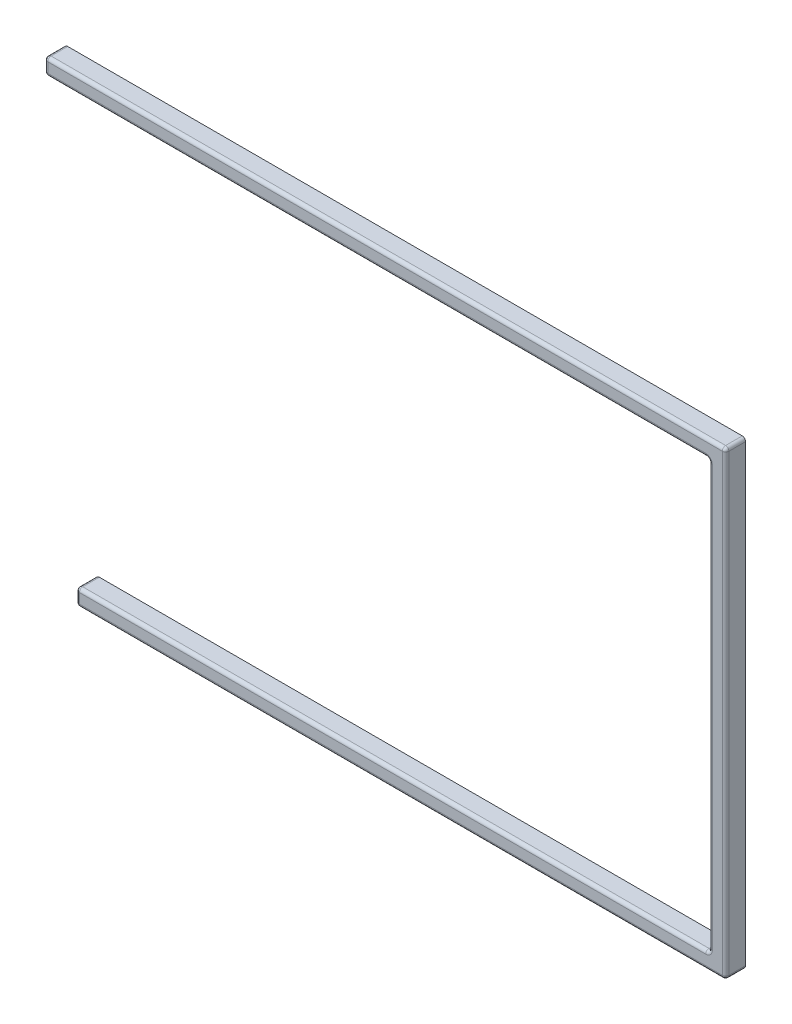
from build123d import *

# Parameters (mm, degrees)
MODEL_W                = 13.999
MODEL_H                = 13.99947
MODEL_W_2              = 13.9993
MODEL_H_2              = 13.99948
MODEL_W_3              = 14.0009
MODEL_H_3              = 13.9994
MODEL_W_4              = 14
MODEL_W_5              = 13.9994
MODEL_H_4              = 13.9992
MODEL_W_6              = 13.9998
MODEL_W_7              = 13.99955
MODEL_W_8              = 14.0007
MODEL_W_9              = 14.001
MODEL_W_10             = 13.99954
MODEL_H_5              = 13.999
EXTRUDE_1_DEPTH        = 3
EXTRUDE_START          = -3
EXTRUDE_2_DEPTH        = 6
CUT_EXTRUDE_START      = -3
SKETCH_2_R             = 1.25
CUT_EXTRUDE_1_DEPTH    = 3.5
FILLET_1_R             = 1
PATTERN_LINEAR_1_COUNT = 3
PATTERN_LINEAR_1_PITCH = 90
SKETCH_3_R             = 1.25
CUT_EXTRUDE_2_DEPTH    = 3.5
PATTERN_LINEAR_2_COUNT = 3
PATTERN_LINEAR_2_PITCH = 70
CUT_EXTRUDE_3_DEPTH    = 10
FILLET_2_R             = 1


with BuildPart() as part:
    # Model → 凸台-拉伸1 (new body)
    with BuildSketch(Plane.XY):
        Polygon((4.85693, 129.021), (204.883, 129.021), (204.883, 0.434082), (14.38193, 0.434082), (14.38193, 24.241), (23.90693, 24.241), (23.90693, 43.291), (14.38193, 43.291), (14.38193, 62.341), (9.61893, 62.341), (9.61893, 81.391), (0.09393, 81.391), (0.09393, 109.971), (4.85693, 109.971), align=None)
        with Locations((152.4945, 9.959765)):
            Rectangle(MODEL_W, MODEL_H, mode=Mode.SUBTRACT)
        with Locations((171.5445, 9.959765)):
            Rectangle(MODEL_W, MODEL_H, mode=Mode.SUBTRACT)
        with Locations((190.5945, 9.959765)):
            Rectangle(MODEL_W, MODEL_H, mode=Mode.SUBTRACT)
        Polygon((33.5759, 21.722), (33.5759, 17.0215), (32.0504, 17.0215), (32.0504, 20.2517), (30.3251, 20.2517), (30.3251, 21.1722), (27.0261, 21.1722), (27.0261, 20.2517), (25.3008, 20.2517), (25.3008, 17.0215), (24.4753, 17.0215), (24.4753, 14.2227), (25.3008, 14.2227), (25.3008, 7.95267), (27.0261, 7.95267), (27.0261, 6.97286), (30.3251, 6.97286), (30.3251, 7.95267), (32.0504, 7.95267), (32.0504, 12.4216), (33.5759, 12.4216), (33.5759, 7.72252), (47.5753, 7.72252), (47.5753, 12.4216), (49.101, 12.4216), (49.101, 7.95267), (50.8247, 7.95267), (50.8247, 6.97286), (54.1253, 6.97286), (54.1253, 7.95267), (55.8504, 7.95267), (55.8504, 14.2227), (56.6759, 14.2227), (56.6759, 17.0215), (55.8504, 17.0215), (55.8504, 20.2517), (54.1253, 20.2517), (54.1253, 21.1722), (50.8247, 21.1722), (50.8247, 20.2517), (49.101, 20.2517), (49.101, 17.0215), (47.5753, 17.0215), (47.5753, 21.722), align=None, mode=Mode.SUBTRACT)
        with Locations((78.67565, 14.72226)):
            Rectangle(MODEL_W_2, MODEL_H_2, mode=Mode.SUBTRACT)
        with Locations((102.48755, 14.72226)):
            Rectangle(MODEL_W_3, MODEL_H_2, mode=Mode.SUBTRACT)
        with Locations((126.3005, 14.72226)):
            Rectangle(MODEL_W, MODEL_H_2, mode=Mode.SUBTRACT)
        with Locations((171.5445, 29.0097)):
            Rectangle(MODEL_W, MODEL_H_3, mode=Mode.SUBTRACT)
        with Locations((33.43185, 33.7722)):
            Rectangle(MODEL_W_2, MODEL_H_3, mode=Mode.SUBTRACT)
        with Locations((52.48185, 33.7722)):
            Rectangle(MODEL_W_2, MODEL_H_3, mode=Mode.SUBTRACT)
        with Locations((71.53185, 33.7722)):
            Rectangle(MODEL_W_2, MODEL_H_3, mode=Mode.SUBTRACT)
        with Locations((90.58185, 33.7722)):
            Rectangle(MODEL_W_2, MODEL_H_3, mode=Mode.SUBTRACT)
        with Locations((109.632, 33.7722)):
            Rectangle(MODEL_W_4, MODEL_H_3, mode=Mode.SUBTRACT)
        with Locations((135.8255, 33.7722)):
            Rectangle(MODEL_W, MODEL_H_3, mode=Mode.SUBTRACT)
        with Locations((195.357, 33.7722)):
            Rectangle(MODEL_W_4, MODEL_H_3, mode=Mode.SUBTRACT)
        Polygon((143.112, 59.8219), (143.112, 55.1215), (141.588, 55.1215), (141.588, 58.3516), (139.863, 58.3516), (139.863, 59.2723), (136.562, 59.2723), (136.562, 58.3516), (134.837, 58.3516), (134.837, 55.1215), (134.013, 55.1215), (134.013, 52.3226), (134.837, 52.3226), (134.837, 46.0527), (136.562, 46.0527), (136.562, 45.0716), (139.863, 45.0716), (139.863, 46.0527), (141.588, 46.0527), (141.588, 50.5217), (143.112, 50.5217), (143.112, 45.8227), (157.113, 45.8227), (157.113, 50.5217), (158.637, 50.5217), (158.637, 46.0527), (160.362, 46.0527), (160.362, 45.0716), (163.663, 45.0716), (163.663, 46.0527), (165.388, 46.0527), (165.388, 52.3226), (166.212, 52.3226), (166.212, 55.1215), (165.388, 55.1215), (165.388, 58.3516), (163.663, 58.3516), (163.663, 59.2723), (160.362, 59.2723), (160.362, 58.3516), (158.637, 58.3516), (158.637, 55.1215), (157.113, 55.1215), (157.113, 59.8219), align=None, mode=Mode.SUBTRACT)
        with Locations((23.9069, 52.8223)):
            Rectangle(MODEL_W_5, MODEL_H_4, mode=Mode.SUBTRACT)
        with Locations((42.95685, 52.8223)):
            Rectangle(MODEL_W_2, MODEL_H_4, mode=Mode.SUBTRACT)
        with Locations((62.00685, 52.8223)):
            Rectangle(MODEL_W_2, MODEL_H_4, mode=Mode.SUBTRACT)
        with Locations((81.05685, 52.8223)):
            Rectangle(MODEL_W_2, MODEL_H_4, mode=Mode.SUBTRACT)
        with Locations((100.1071, 52.8223)):
            Rectangle(MODEL_W_6, MODEL_H_4, mode=Mode.SUBTRACT)
        with Locations((119.157, 52.8223)):
            Rectangle(MODEL_W_4, MODEL_H_4, mode=Mode.SUBTRACT)
        with Locations((195.357, 52.8223)):
            Rectangle(MODEL_W_4, MODEL_H_4, mode=Mode.SUBTRACT)
        with Locations((19.1444, 71.8723)):
            Rectangle(MODEL_W_5, MODEL_H_4, mode=Mode.SUBTRACT)
        with Locations((38.19435, 71.8723)):
            Rectangle(MODEL_W_2, MODEL_H_4, mode=Mode.SUBTRACT)
        with Locations((57.24435, 71.8723)):
            Rectangle(MODEL_W_2, MODEL_H_4, mode=Mode.SUBTRACT)
        with Locations((76.29435, 71.8723)):
            Rectangle(MODEL_W_2, MODEL_H_4, mode=Mode.SUBTRACT)
        with Locations((95.34435, 71.8723)):
            Rectangle(MODEL_W_2, MODEL_H_4, mode=Mode.SUBTRACT)
        with Locations((114.3945, 71.8723)):
            Rectangle(MODEL_W, MODEL_H_4, mode=Mode.SUBTRACT)
        with Locations((133.4445, 71.8723)):
            Rectangle(MODEL_W, MODEL_H_4, mode=Mode.SUBTRACT)
        with Locations((157.257, 71.8723)):
            Rectangle(MODEL_W_4, MODEL_H_4, mode=Mode.SUBTRACT)
        with Locations((195.357, 71.8723)):
            Rectangle(MODEL_W_4, MODEL_H_4, mode=Mode.SUBTRACT)
        Polygon((145.493, 97.9219), (145.493, 93.2215), (143.969, 93.2215), (143.969, 96.4516), (142.244, 96.4516), (142.244, 97.3723), (138.943, 97.3723), (138.943, 96.4516), (137.218, 96.4516), (137.218, 93.2215), (136.394, 93.2215), (136.394, 90.4226), (137.218, 90.4226), (137.218, 84.1527), (138.943, 84.1527), (138.943, 83.1716), (142.244, 83.1716), (142.244, 84.1527), (143.969, 84.1527), (143.969, 88.6217), (145.493, 88.6217), (145.493, 83.9227), (159.494, 83.9227), (159.494, 88.6217), (161.018, 88.6217), (161.018, 84.1527), (162.743, 84.1527), (162.743, 83.1716), (166.044, 83.1716), (166.044, 84.1527), (167.768, 84.1527), (167.768, 90.4226), (168.593, 90.4226), (168.593, 93.2215), (167.768, 93.2215), (167.768, 96.4516), (166.044, 96.4516), (166.044, 97.3723), (162.743, 97.3723), (162.743, 96.4516), (161.018, 96.4516), (161.018, 93.2215), (159.494, 93.2215), (159.494, 97.9219), align=None, mode=Mode.SUBTRACT)
        with Locations((9.619425, 90.9223)):
            Rectangle(MODEL_W_7, MODEL_H_4, mode=Mode.SUBTRACT)
        with Locations((28.66935, 90.9223)):
            Rectangle(MODEL_W_2, MODEL_H_4, mode=Mode.SUBTRACT)
        with Locations((47.71935, 90.9223)):
            Rectangle(MODEL_W_2, MODEL_H_4, mode=Mode.SUBTRACT)
        with Locations((66.76935, 90.9223)):
            Rectangle(MODEL_W_2, MODEL_H_4, mode=Mode.SUBTRACT)
        with Locations((85.81935, 90.9223)):
            Rectangle(MODEL_W_2, MODEL_H_4, mode=Mode.SUBTRACT)
        with Locations((104.86865, 90.9223)):
            Rectangle(MODEL_W_8, MODEL_H_4, mode=Mode.SUBTRACT)
        with Locations((123.9185, 90.9223)):
            Rectangle(MODEL_W_9, MODEL_H_4, mode=Mode.SUBTRACT)
        with Locations((195.357, 90.9223)):
            Rectangle(MODEL_W_4, MODEL_H_4, mode=Mode.SUBTRACT)
        with Locations((14.38193, 119.4975)):
            Rectangle(MODEL_W_10, MODEL_H_5, mode=Mode.SUBTRACT)
        with Locations((33.43185, 119.4975)):
            Rectangle(MODEL_W_2, MODEL_H_5, mode=Mode.SUBTRACT)
        with Locations((52.48185, 119.4975)):
            Rectangle(MODEL_W_2, MODEL_H_5, mode=Mode.SUBTRACT)
        with Locations((71.53185, 119.4975)):
            Rectangle(MODEL_W_2, MODEL_H_5, mode=Mode.SUBTRACT)
        with Locations((90.58185, 119.4975)):
            Rectangle(MODEL_W_2, MODEL_H_5, mode=Mode.SUBTRACT)
        with Locations((109.632, 119.4975)):
            Rectangle(MODEL_W_4, MODEL_H_5, mode=Mode.SUBTRACT)
        with Locations((128.682, 119.4975)):
            Rectangle(MODEL_W_4, MODEL_H_5, mode=Mode.SUBTRACT)
        with Locations((152.4945, 119.4975)):
            Rectangle(MODEL_W, MODEL_H_5, mode=Mode.SUBTRACT)
        with Locations((171.5445, 119.4975)):
            Rectangle(MODEL_W, MODEL_H_5, mode=Mode.SUBTRACT)
        with Locations((192.9755, 119.4975)):
            Rectangle(MODEL_W, MODEL_H_5, mode=Mode.SUBTRACT)
    extrude(amount=EXTRUDE_1_DEPTH)

    # 草图1 → 凸台-拉伸2 (add)
    with BuildSketch(Plane.XY.offset(3).offset(EXTRUDE_START)):
        Polygon((14.38193, -4.565918), (209.883, -4.565918), (209.883, 134.021), (4.85693, 134.021), (4.85693, 129.021), (204.883, 129.021), (204.883, 0.434082), (14.38193, 0.434082), align=None)
    extrude(amount=EXTRUDE_2_DEPTH)

    # 草图2 → 切除-拉伸1 (cut)
    with BuildSketch(Plane.XY.offset(3).offset(CUT_EXTRUDE_START)):
        with Locations((7.85693, 131.521)):
            Circle(SKETCH_2_R)
        with Locations((17.38193, -2.065918)):
            Circle(SKETCH_2_R)
    cut_extrude_1 = extrude(amount=CUT_EXTRUDE_1_DEPTH, mode=Mode.SUBTRACT)

    # 圆角1
    fillet_1_edges = [part.edges().sort_by_distance(p)[0] for p in [
        (209.883, 134.021, 3),
        (4.85693, 134.021, 3),
        (14.38193, -4.565918, 3),
        (209.883, -4.565918, 3),
    ]]
    fillet(fillet_1_edges, radius=FILLET_1_R)

    # 阵列(线性)1: 切除-拉伸1 ×3
    with Locations(*[(i * PATTERN_LINEAR_1_PITCH, 0, 0) for i in range(1, PATTERN_LINEAR_1_COUNT)]):
        add(cut_extrude_1, mode=Mode.SUBTRACT)

    # 草图3 → 切除-拉伸2 (cut)
    with BuildSketch(Plane.XY.offset(3).offset(CUT_EXTRUDE_START)):
        with Locations((207.383, 35.434082)):
            Circle(SKETCH_3_R)
    cut_extrude_2 = extrude(amount=CUT_EXTRUDE_2_DEPTH, mode=Mode.SUBTRACT)

    # 阵列(线性)2: 切除-拉伸2 ×3
    with Locations(*[(0, i * PATTERN_LINEAR_2_PITCH, 0) for i in range(1, PATTERN_LINEAR_2_COUNT)]):
        add(cut_extrude_2, mode=Mode.SUBTRACT)

    # 草图4 → 切除-拉伸3 (cut)
    with BuildSketch(Plane.XY.offset(3)):
        Polygon((14.38193, 0.434082), (204.883, 0.434082), (204.883, 129.021), (4.85693, 129.021), (0.09393, 129.021), (0.09393, 0.434082), align=None)
    extrude(amount=-CUT_EXTRUDE_3_DEPTH, mode=Mode.SUBTRACT)

    # 圆角2
    fillet_2_edges = [part.edges().sort_by_distance(p)[0] for p in [
        (104.869965, 129.021, 6),
        (4.85693, 129.021, 3),
        (109.632465, 0.434082, 6),
        (204.883, 0.434082, 3),
        (204.883, 64.727541, 6),
        (204.883, 129.021, 3),
        (4.85693, 131.021, 6),
        (14.38193, 0.434082, 3),
        (112.132465, -4.565918, 6),
        (14.38193, -1.565918, 6),
        (107.369965, 134.021, 6),
        (209.883, 64.727541, 6),
        (209.590106781, -4.273024781, 6),
        (209.590106781, 133.728106781, 6),
        (5.149823219, 133.728106781, 6),
        (14.674823219, -4.273024781, 6),
    ]]
    fillet(fillet_2_edges, radius=FILLET_2_R)


solid = part.part
